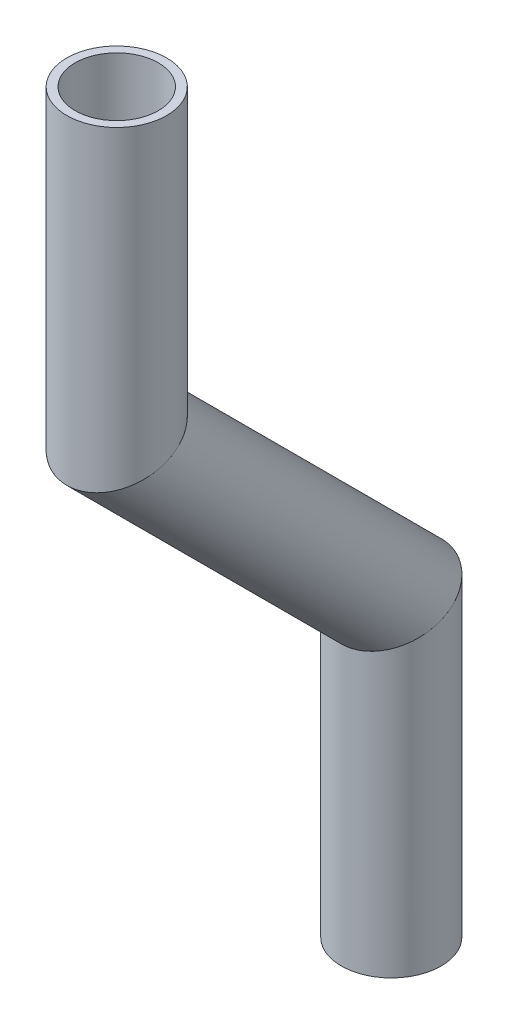
from build123d import *

# Parameters (mm, degrees)
SKETCH11_R                = 6.35
SKETCH11_R_2              = 5.2832
PIPE_0_5_SCH_40_1_DEPTH   = 42.819743879
SKETCH11_ON_SEGMENT_2_R   = 6.35
SKETCH11_ON_SEGMENT_2_R_2 = 5.2832
PIPE_0_5_SCH_40_1_2_DEPTH = 58.810656537
SKETCH11_ON_SEGMENT_3_R   = 6.35
SKETCH11_ON_SEGMENT_3_R_2 = 5.2832
PIPE_0_5_SCH_40_1_3_DEPTH = 42.819743879


with BuildPart() as part:
    # Sketch11 → Pipe 0.5 SCH 40(1) (new body)
    with BuildSketch(Plane(origin=(0, -435.341064838, 362.765281468), x_dir=(0, 0, -1), z_dir=(0, -1, 0))):
        Circle(SKETCH11_R)
        Circle(SKETCH11_R_2, mode=Mode.SUBTRACT)
    extrude(amount=PIPE_0_5_SCH_40_1_DEPTH)

    # Pipe 0.5 SCH 40(1) mitre 1
    split(bisect_by=Plane(origin=(0, -473.441064838, 362.765281468), x_dir=(-1, 0, 0), z_dir=(0, 0.923879533, 0.382683432)), keep=Keep.TOP)


with BuildPart() as body_2:
    # Sketch11 on segment 2 (carried to segment 2) → Pipe 0.5 SCH 40_1 2 (new body)
    with BuildSketch(Plane(origin=(0, -470.103701936, 366.10264437), x_dir=(0, 0.707106781, -0.707106781), z_dir=(0, -0.707106781, -0.707106781))):
        Circle(SKETCH11_ON_SEGMENT_2_R)
        Circle(SKETCH11_ON_SEGMENT_2_R_2, mode=Mode.SUBTRACT)
    extrude(amount=PIPE_0_5_SCH_40_1_2_DEPTH)

    # Pipe 0.5 SCH 40_1 2 mitre 1
    split(bisect_by=Plane(origin=(0, -473.441064838, 362.765281468), x_dir=(1, 0, 0), z_dir=(0, -0.923879533, -0.382683432)), keep=Keep.TOP)

    # Pipe 0.5 SCH 40_1 2 mitre 2
    split(bisect_by=Plane(origin=(0, -508.351753077, 327.854593229), x_dir=(-1, 0, 0), z_dir=(0, 0.923879533, 0.382683432)), keep=Keep.TOP)


with BuildPart() as body_3:
    # Sketch11 on segment 3 (carried to segment 3) → Pipe 0.5 SCH 40_1 3 (new body)
    with BuildSketch(Plane(origin=(0, -503.632009198, 327.854593229), x_dir=(0, 0, -1), z_dir=(0, -1, 0))):
        Circle(SKETCH11_ON_SEGMENT_3_R)
        Circle(SKETCH11_ON_SEGMENT_3_R_2, mode=Mode.SUBTRACT)
    extrude(amount=PIPE_0_5_SCH_40_1_3_DEPTH)

    # Pipe 0.5 SCH 40_1 3 mitre 1
    split(bisect_by=Plane(origin=(0, -508.351753077, 327.854593229), x_dir=(1, 0, 0), z_dir=(0, -0.923879533, -0.382683432)), keep=Keep.TOP)


solid = Compound([part.part, body_2.part, body_3.part])
